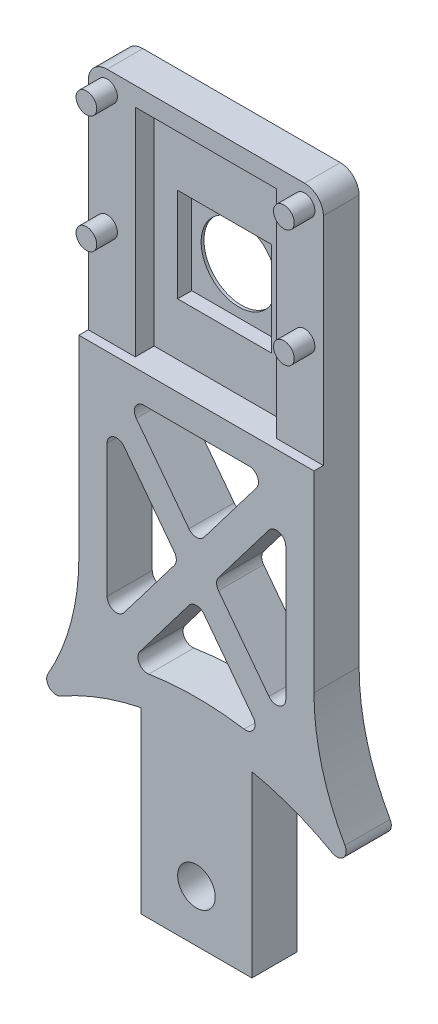
from build123d import *

# Parameters (mm, degrees)
SKIZZE1_W                            = 25
SKIZZE1_H                            = 75
AUFSATZ_LINEAR_AUSTRAGEN1_DEPTH      = 4.8
SCHNITT_LINEAR_AUSTRAGEN1_DEPTH      = 5
SKIZZE3_W                            = 25
SKIZZE3_H                            = 25
SCHNITT_LINEAR_AUSTRAGEN2_DEPTH      = 1
SKIZZE4_W                            = 15
SKIZZE4_H                            = 23
SCHNITT_LINEAR_AUSTRAGEN3_DEPTH      = 2
SKIZZE5_R                            = 4
SCHNITT_LINEAR_AUSTRAGEN4_DEPTH      = 2.8
SKIZZE6_W                            = 10
SKIZZE6_H                            = 10
SKIZZE6_R                            = 4
SCHNITT_LINEAR_AUSTRAGEN5_DEPTH      = 1.5
AUFSATZ_LINEAR_AUSTRAGEN2_DEPTH      = 6
SKIZZE8_R                            = 2
SCHNITT_LINEAR_AUSTRAGEN6_DEPTH      = 2.2
SCHNITT_LINEAR_AUSTRAGEN6_DEPTH_BACK = 5.8
SKIZZE9_W                            = 6.6
SKIZZE9_H                            = 19
SCHNITT_LINEAR_AUSTRAGEN7_DEPTH      = 5.8
AUFSATZ_LINEAR_AUSTRAGEN3_DEPTH      = 4.8
VERRUNDUNG1_R                        = 2
VERRUNDUNG2_R                        = 1
SCHNITT_LINEAR_AUSTRAGEN8_DEPTH      = 5.8000001
VERRUNDUNG3_R                        = 1


with BuildPart() as part:
    # Skizze1 → Aufsatz-Linear austragen1 (new body)
    with BuildSketch(Plane.XY):
        with Locations((0, 37.5)):
            Rectangle(SKIZZE1_W, SKIZZE1_H)
    extrude(amount=AUFSATZ_LINEAR_AUSTRAGEN1_DEPTH)

    # Skizze2 → Schnitt-Linear austragen1 (cut)
    with BuildSketch(Plane.XY.offset(4.8)):
        with BuildLine():
            ThreePointArc((-9.4, 73), (-11.277817459, 73.777817459), (-10.5, 71.9))
            Line((-10.5, 71.9), (-10.5, 73))
            Line((-10.5, 73), (-9.4, 73))
        make_face()
        with BuildLine():
            Line((-10.5, 73), (-10.5, 71.9))
            ThreePointArc((-10.5, 71.9), (-9.722182541, 72.222182541), (-9.4, 73))
            Line((-9.4, 73), (-10.5, 73))
        make_face()
        with BuildLine():
            ThreePointArc((9.4, 73), (9.722182541, 72.222182541), (10.5, 71.9))
            Line((10.5, 71.9), (10.5, 73))
            Line((10.5, 73), (9.4, 73))
        make_face()
        with BuildLine():
            Line((10.5, 73), (10.5, 71.9))
            ThreePointArc((10.5, 71.9), (11.277817459, 72.222182541), (11.6, 73))
            ThreePointArc((11.6, 73), (10.5, 74.1), (9.4, 73))
            Line((9.4, 73), (10.5, 73))
        make_face()
        with BuildLine():
            ThreePointArc((9.4, 73), (9.722182541, 72.222182541), (10.5, 71.9))
            Line((10.5, 71.9), (10.5, 73))
            Line((10.5, 73), (9.4, 73))
        make_face()
        with BuildLine():
            Line((10.5, 73), (10.5, 71.9))
            ThreePointArc((10.5, 71.9), (11.277817459, 72.222182541), (11.6, 73))
            ThreePointArc((11.6, 73), (10.5, 74.1), (9.4, 73))
            Line((9.4, 73), (10.5, 73))
        make_face()
        with BuildLine():
            ThreePointArc((-10.5, 61.6), (-11.277817459, 59.722182541), (-9.4, 60.5))
            Line((-9.4, 60.5), (-10.5, 60.5))
            Line((-10.5, 60.5), (-10.5, 61.6))
        make_face()
        with BuildLine():
            Line((-10.5, 60.5), (-9.4, 60.5))
            ThreePointArc((-9.4, 60.5), (-9.722182541, 61.277817459), (-10.5, 61.6))
            Line((-10.5, 61.6), (-10.5, 60.5))
        make_face()
        with BuildLine():
            ThreePointArc((-10.5, 61.6), (-11.277817459, 59.722182541), (-9.4, 60.5))
            Line((-9.4, 60.5), (-10.5, 60.5))
            Line((-10.5, 60.5), (-10.5, 61.6))
        make_face()
        with BuildLine():
            Line((-10.5, 60.5), (-9.4, 60.5))
            ThreePointArc((-9.4, 60.5), (-9.722182541, 61.277817459), (-10.5, 61.6))
            Line((-10.5, 61.6), (-10.5, 60.5))
        make_face()
        with BuildLine():
            ThreePointArc((10.5, 61.6), (9.722182541, 61.277817459), (9.4, 60.5))
            Line((9.4, 60.5), (10.5, 60.5))
            Line((10.5, 60.5), (10.5, 61.6))
        make_face()
        with BuildLine():
            Line((10.5, 60.5), (9.4, 60.5))
            ThreePointArc((9.4, 60.5), (10.5, 59.4), (11.6, 60.5))
            ThreePointArc((11.6, 60.5), (11.277817459, 61.277817459), (10.5, 61.6))
            Line((10.5, 61.6), (10.5, 60.5))
        make_face()
        with BuildLine():
            ThreePointArc((10.5, 61.6), (9.722182541, 61.277817459), (9.4, 60.5))
            Line((9.4, 60.5), (10.5, 60.5))
            Line((10.5, 60.5), (10.5, 61.6))
        make_face()
        with BuildLine():
            Line((10.5, 60.5), (9.4, 60.5))
            ThreePointArc((9.4, 60.5), (10.5, 59.4), (11.6, 60.5))
            ThreePointArc((11.6, 60.5), (11.277817459, 61.277817459), (10.5, 61.6))
            Line((10.5, 61.6), (10.5, 60.5))
        make_face()
        with BuildLine():
            ThreePointArc((-9.4, 73), (-11.277817459, 73.777817459), (-10.5, 71.9))
            Line((-10.5, 71.9), (-10.5, 73))
            Line((-10.5, 73), (-9.4, 73))
        make_face()
        with BuildLine():
            Line((-10.5, 73), (-10.5, 71.9))
            ThreePointArc((-10.5, 71.9), (-9.722182541, 72.222182541), (-9.4, 73))
            Line((-9.4, 73), (-10.5, 73))
        make_face()
    extrude(amount=-SCHNITT_LINEAR_AUSTRAGEN1_DEPTH, mode=Mode.SUBTRACT)

    # Skizze3 → Schnitt-Linear austragen2 (cut)
    with BuildSketch(Plane.XY.offset(4.8)):
        with Locations((0, 62.5)):
            Rectangle(SKIZZE3_W, SKIZZE3_H)
    extrude(amount=-SCHNITT_LINEAR_AUSTRAGEN2_DEPTH, mode=Mode.SUBTRACT)

    # Skizze4 → Schnitt-Linear austragen3 (cut)
    with BuildSketch(Plane.XY.offset(3.8)):
        with Locations((0, 61.5)):
            Rectangle(SKIZZE4_W, SKIZZE4_H)
    extrude(amount=-SCHNITT_LINEAR_AUSTRAGEN3_DEPTH, mode=Mode.SUBTRACT)

    # Skizze5 → Schnitt-Linear austragen4 (cut, through all)
    with BuildSketch(Plane.XY.offset(1.8)):
        with Locations((0, 60.6)):
            Circle(SKIZZE5_R)
    extrude(amount=-SCHNITT_LINEAR_AUSTRAGEN4_DEPTH, mode=Mode.SUBTRACT)

    # Skizze6 → Schnitt-Linear austragen5 (cut)
    with BuildSketch(Plane.XY.offset(1.8)):
        with Locations((0, 60.6)):
            Rectangle(SKIZZE6_W, SKIZZE6_H)
        with Locations((0, 60.6)):
            Circle(SKIZZE6_R, mode=Mode.SUBTRACT)
    extrude(amount=-SCHNITT_LINEAR_AUSTRAGEN5_DEPTH, mode=Mode.SUBTRACT)

    # Skizze7 → Aufsatz-Linear austragen2 (add)
    with BuildSketch(Plane.XY):
        with BuildLine():
            ThreePointArc((-10.5, 61.6), (-11.277817459, 59.722182541), (-9.4, 60.5))
            Line((-9.4, 60.5), (-10.5, 60.5))
            Line((-10.5, 60.5), (-10.5, 61.6))
        make_face()
        with BuildLine():
            Line((-10.5, 60.5), (-9.4, 60.5))
            ThreePointArc((-9.4, 60.5), (-9.722182541, 61.277817459), (-10.5, 61.6))
            Line((-10.5, 61.6), (-10.5, 60.5))
        make_face()
        with BuildLine():
            ThreePointArc((-9.4, 73), (-11.277817459, 73.777817459), (-10.5, 71.9))
            Line((-10.5, 71.9), (-10.5, 73))
            Line((-10.5, 73), (-9.4, 73))
        make_face()
        with BuildLine():
            Line((-10.5, 73), (-10.5, 71.9))
            ThreePointArc((-10.5, 71.9), (-9.722182541, 72.222182541), (-9.4, 73))
            Line((-9.4, 73), (-10.5, 73))
        make_face()
        with BuildLine():
            ThreePointArc((10.5, 61.6), (9.722182541, 61.277817459), (9.4, 60.5))
            Line((9.4, 60.5), (10.5, 60.5))
            Line((10.5, 60.5), (10.5, 61.6))
        make_face()
        with BuildLine():
            Line((10.5, 60.5), (9.4, 60.5))
            ThreePointArc((9.4, 60.5), (10.5, 59.4), (11.6, 60.5))
            ThreePointArc((11.6, 60.5), (11.277817459, 61.277817459), (10.5, 61.6))
            Line((10.5, 61.6), (10.5, 60.5))
        make_face()
        with BuildLine():
            ThreePointArc((9.4, 73), (9.722182541, 72.222182541), (10.5, 71.9))
            Line((10.5, 71.9), (10.5, 73))
            Line((10.5, 73), (9.4, 73))
        make_face()
        with BuildLine():
            Line((10.5, 73), (10.5, 71.9))
            ThreePointArc((10.5, 71.9), (11.277817459, 72.222182541), (11.6, 73))
            ThreePointArc((11.6, 73), (10.5, 74.1), (9.4, 73))
            Line((9.4, 73), (10.5, 73))
        make_face()
        with BuildLine():
            ThreePointArc((9.4, 73), (9.722182541, 72.222182541), (10.5, 71.9))
            Line((10.5, 71.9), (10.5, 73))
            Line((10.5, 73), (9.4, 73))
        make_face()
        with BuildLine():
            Line((10.5, 73), (10.5, 71.9))
            ThreePointArc((10.5, 71.9), (11.277817459, 72.222182541), (11.6, 73))
            ThreePointArc((11.6, 73), (10.5, 74.1), (9.4, 73))
            Line((9.4, 73), (10.5, 73))
        make_face()
        with BuildLine():
            ThreePointArc((10.5, 61.6), (9.722182541, 61.277817459), (9.4, 60.5))
            Line((9.4, 60.5), (10.5, 60.5))
            Line((10.5, 60.5), (10.5, 61.6))
        make_face()
        with BuildLine():
            Line((10.5, 60.5), (9.4, 60.5))
            ThreePointArc((9.4, 60.5), (10.5, 59.4), (11.6, 60.5))
            ThreePointArc((11.6, 60.5), (11.277817459, 61.277817459), (10.5, 61.6))
            Line((10.5, 61.6), (10.5, 60.5))
        make_face()
        with BuildLine():
            ThreePointArc((-10.5, 61.6), (-11.277817459, 59.722182541), (-9.4, 60.5))
            Line((-9.4, 60.5), (-10.5, 60.5))
            Line((-10.5, 60.5), (-10.5, 61.6))
        make_face()
        with BuildLine():
            Line((-10.5, 60.5), (-9.4, 60.5))
            ThreePointArc((-9.4, 60.5), (-9.722182541, 61.277817459), (-10.5, 61.6))
            Line((-10.5, 61.6), (-10.5, 60.5))
        make_face()
        with BuildLine():
            ThreePointArc((-9.4, 73), (-11.277817459, 73.777817459), (-10.5, 71.9))
            Line((-10.5, 71.9), (-10.5, 73))
            Line((-10.5, 73), (-9.4, 73))
        make_face()
        with BuildLine():
            Line((-10.5, 73), (-10.5, 71.9))
            ThreePointArc((-10.5, 71.9), (-9.722182541, 72.222182541), (-9.4, 73))
            Line((-9.4, 73), (-10.5, 73))
        make_face()
    extrude(amount=AUFSATZ_LINEAR_AUSTRAGEN2_DEPTH)

    # Skizze8 → Schnitt-Linear austragen6 (cut, two sides)
    with BuildSketch(Plane.XY.offset(4.8)) as schnitt_linear_austragen6_sk:
        with Locations((0, 5.5)):
            Circle(SKIZZE8_R)
    extrude(amount=SCHNITT_LINEAR_AUSTRAGEN6_DEPTH, mode=Mode.SUBTRACT)
    extrude(schnitt_linear_austragen6_sk.sketch, amount=-SCHNITT_LINEAR_AUSTRAGEN6_DEPTH_BACK, mode=Mode.SUBTRACT)

    # Skizze9 → Schnitt-Linear austragen7 (cut, through all)
    with BuildSketch(Plane.XY.offset(4.8)):
        with Locations((-9.2, 9.5)):
            Rectangle(SKIZZE9_W, SKIZZE9_H)
        with Locations((9.2, 9.5)):
            Rectangle(SKIZZE9_W, SKIZZE9_H)
    extrude(amount=-SCHNITT_LINEAR_AUSTRAGEN7_DEPTH, mode=Mode.SUBTRACT)

    # Skizze10 → Aufsatz-Linear austragen3 (add)
    with BuildSketch(Plane.XY.offset(4.8)):
        with BuildLine():
            ThreePointArc((-20.231626451, 11.490217952), (-13.594656371, 16.254350305), (-5.9, 19))
            Line((-5.9, 19), (-12.5, 19))
            Line((-12.5, 19), (-12.5, 29.567918994))
            ThreePointArc((-12.5, 29.567918994), (-14.514033208, 19.73708329), (-20.231626451, 11.490217952))
        make_face()
        with BuildLine():
            ThreePointArc((5.9, 19), (13.594656371, 16.254350305), (20.231626451, 11.490217952))
            ThreePointArc((20.231626451, 11.490217952), (14.514033208, 19.73708329), (12.5, 29.567918994))
            Line((12.5, 29.567918994), (12.5, 19))
            Line((12.5, 19), (5.9, 19))
        make_face()
    extrude(amount=-AUFSATZ_LINEAR_AUSTRAGEN3_DEPTH)

    # Verrundung1
    verrundung1_edges = [part.edges().sort_by_distance(p)[0] for p in [
        (-12.5, 75, 1.9),
        (12.5, 75, 1.9),
    ]]
    fillet(verrundung1_edges, radius=VERRUNDUNG1_R)

    # Verrundung2
    verrundung2_edges = [part.edges().sort_by_distance(p)[0] for p in [
        (-20.231626451, 11.490217952, 2.4),
        (20.231626451, 11.490217952, 2.4),
    ]]
    fillet(verrundung2_edges, radius=VERRUNDUNG2_R)

    # Skizze12 → Schnitt-Linear austragen8 (cut, through all)
    with BuildSketch(Plane.XY.offset(4.8)):
        Polygon((-1.884038216, 34.5), (-9.5, 44.521002347), (-9.5, 24.478997653), align=None)
        Polygon((0, 36.978997653), (7.615961784, 47), (-7.615961784, 47), align=None)
        Polygon((9.5, 24.478997653), (9.5, 44.521002347), (1.884038216, 34.5), align=None)
        with BuildLine():
            ThreePointArc((7.615961784, 22), (0, 22.902325259), (-7.615961784, 22))
            Line((-7.615961784, 22), (0, 32.021002347))
            Line((0, 32.021002347), (7.615961784, 22))
        make_face()
    extrude(amount=-SCHNITT_LINEAR_AUSTRAGEN8_DEPTH, mode=Mode.SUBTRACT)

    # Verrundung3
    verrundung3_edges = [part.edges().sort_by_distance(p)[0] for p in [
        (1.884038216, 34.5, 2.4),
        (9.5, 44.521002347, 2.4),
        (9.5, 24.478997653, 2.4),
        (0, 36.978997653, 2.4),
        (-7.615961784, 47, 2.4),
        (7.615961784, 47, 2.4),
        (7.615961784, 22, 2.4),
        (-7.615961784, 22, 2.4),
        (0, 32.021002347, 2.4),
        (-1.884038216, 34.5, 2.4),
        (-9.5, 24.478997653, 2.4),
        (-9.5, 44.521002347, 2.4),
    ]]
    fillet(verrundung3_edges, radius=VERRUNDUNG3_R)


solid = part.part
